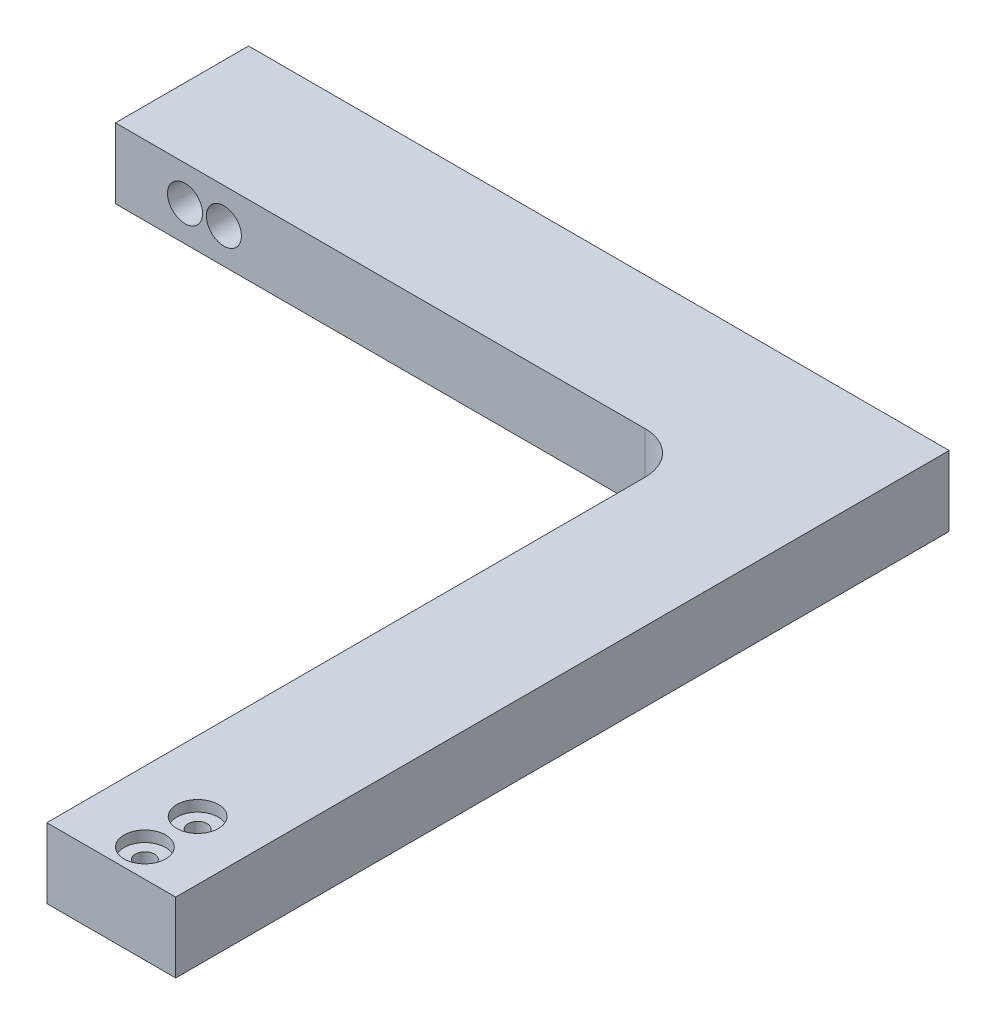
from build123d import *

# Parameters (mm, degrees)
BOSS_EXTRUDE1_DEPTH                                 = 12.7
FILLET1_R                                           = 7.62
CBORE_FOR_5_BINDING_HEAD_MACHINE_SCREW1_D           = 3.4544
CBORE_FOR_5_BINDING_HEAD_MACHINE_SCREW1_DEPTH       = 12.7
CBORE_FOR_5_BINDING_HEAD_MACHINE_SCREW1_CBORE_D     = 7.54126
CBORE_FOR_5_BINDING_HEAD_MACHINE_SCREW1_CBORE_DEPTH = 1.9812
F_1_4_0_25_DIAMETER_HOLE2_D                         = 6.35
F_1_4_0_25_DIAMETER_HOLE2_DEPTH                     = 24.13


with BuildPart() as part:
    # Sketch1 → Boss-Extrude1 (new body)
    with BuildSketch(Plane(origin=(0, 0, 0), x_dir=(1, 0, 0), z_dir=(0, 1, 0))):
        Polygon((-12.7, 39.878), (-116.332, 39.878), (-116.332, 64.008), (10.668, 64.008), (10.668, -76.2), (-12.7, -76.2), align=None)
    extrude(amount=BOSS_EXTRUDE1_DEPTH)

    # Fillet1
    fillet1_edges = [part.edges().sort_by_distance(p)[0] for p in [
        (-12.7, 6.35, -39.878),
    ]]
    fillet(fillet1_edges, radius=FILLET1_R)

    # CBORE for #5 Binding Head Machine Screw1
    with Locations(Plane(origin=(0, 12.7, 0), x_dir=(1, 0, 0), z_dir=(0, 1, 0))):
        with Locations((0, -71.12), (0, -61.560890579)):
            CounterBoreHole(CBORE_FOR_5_BINDING_HEAD_MACHINE_SCREW1_D / 2, CBORE_FOR_5_BINDING_HEAD_MACHINE_SCREW1_CBORE_D / 2, CBORE_FOR_5_BINDING_HEAD_MACHINE_SCREW1_CBORE_DEPTH, depth=CBORE_FOR_5_BINDING_HEAD_MACHINE_SCREW1_DEPTH)

    # 1/4 (0.25) Diameter Hole2
    with Locations(Plane(origin=(0, 0, -64.008), x_dir=(-1, 0, 0), z_dir=(0, 0, -1))):
        with Locations((103.718203887, 6.35), (96.672754807, 6.35)):
            Hole(F_1_4_0_25_DIAMETER_HOLE2_D / 2, depth=F_1_4_0_25_DIAMETER_HOLE2_DEPTH)


solid = part.part
